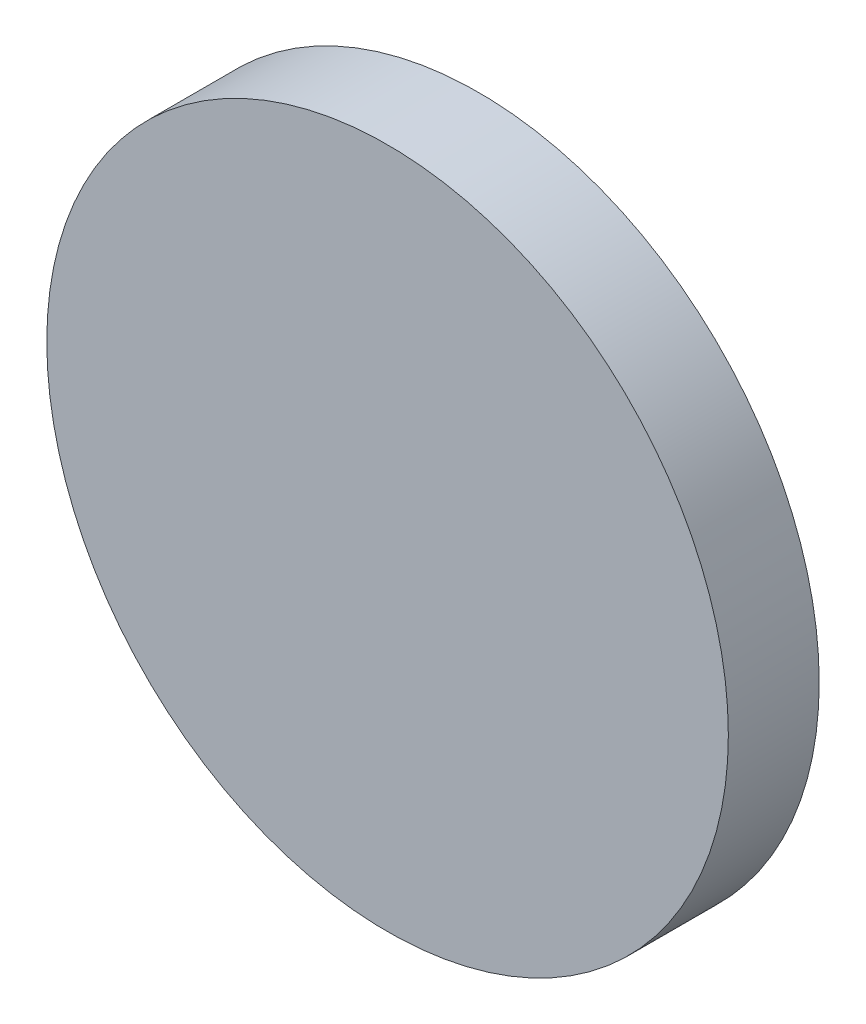
from build123d import *

# Parameters (mm, degrees)
SKETCH1_R           = 75
BOSS_EXTRUDE1_DEPTH = 20


with BuildPart() as part:
    # Sketch1 → Boss-Extrude1 (new body)
    with BuildSketch(Plane.XY):
        Circle(SKETCH1_R)
    extrude(amount=BOSS_EXTRUDE1_DEPTH)


solid = part.part
